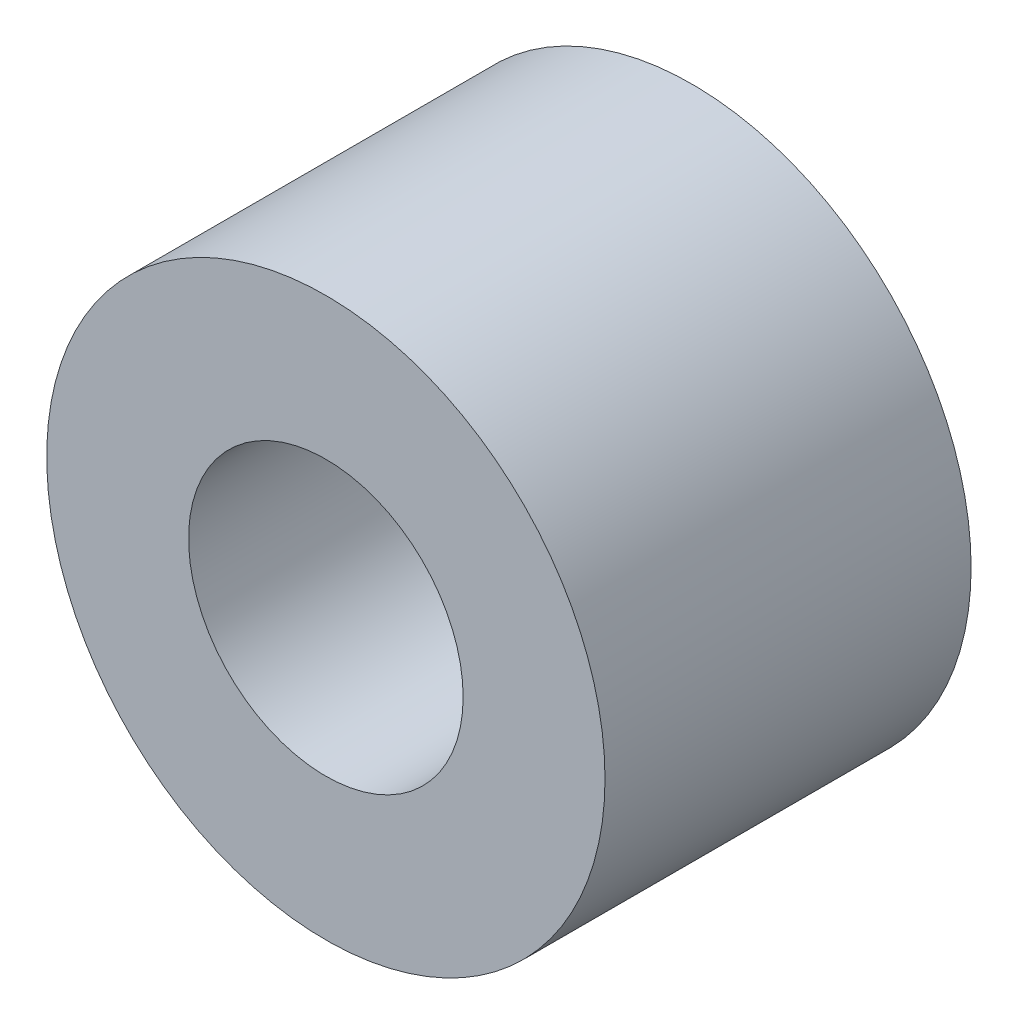
from build123d import *

# Parameters (mm, degrees)
CROQUIS1_R              = 3.05
CROQUIS1_R_2            = 1.5
SALIENTE_EXTRUIR1_DEPTH = 4


with BuildPart() as part:
    # Croquis1 → Saliente-Extruir1 (new body)
    with BuildSketch(Plane.XY):
        Circle(CROQUIS1_R)
        Circle(CROQUIS1_R_2, mode=Mode.SUBTRACT)
    extrude(amount=SALIENTE_EXTRUIR1_DEPTH)


solid = part.part
